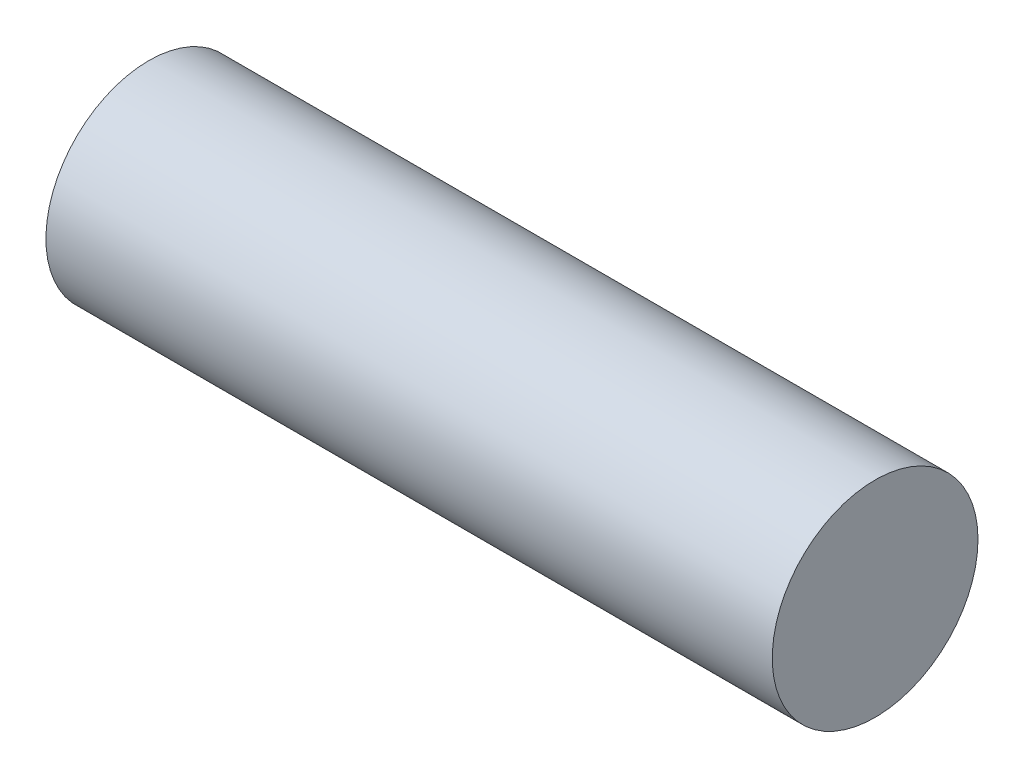
from build123d import *


with BuildPart() as part:
    # Sketch1 → Revolve1 (revolve)
    with BuildSketch(Plane.XY):
        with BuildLine():
            Line((0, 1.65), (11.65, 1.65))
            Line((11.65, 1.65), (11.65, 0))
            Line((11.65, 0), (1.65, 0))
            ThreePointArc((1.65, 0), (1.166726189, 1.166726189), (0, 1.65))
        make_face()
    revolve(axis=Axis((11.65, 0, 0), (-1, 0, 0)))


solid = part.part
